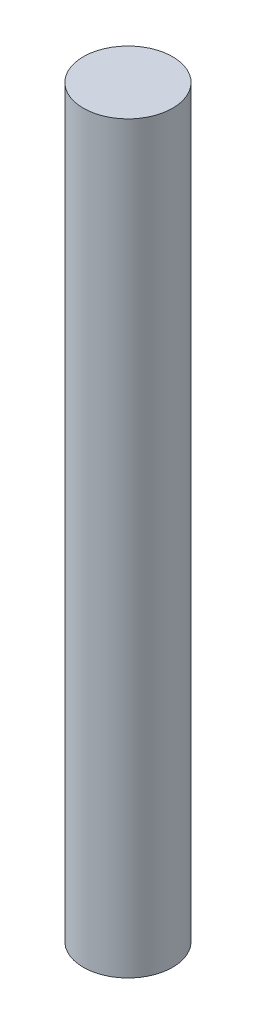
from build123d import *

# Parameters (mm, degrees)
SKETCH_1_R      = 7.5
EXTRUDE_1_DEPTH = 62.5


with BuildPart() as part:
    # 草圖1 → 填料-伸長1 (new body, symmetric)
    with BuildSketch(Plane(origin=(0, 0, 0), x_dir=(1, 0, 0), z_dir=(0, 1, 0))):
        Circle(SKETCH_1_R)
    extrude(amount=EXTRUDE_1_DEPTH, both=True)


solid = part.part
